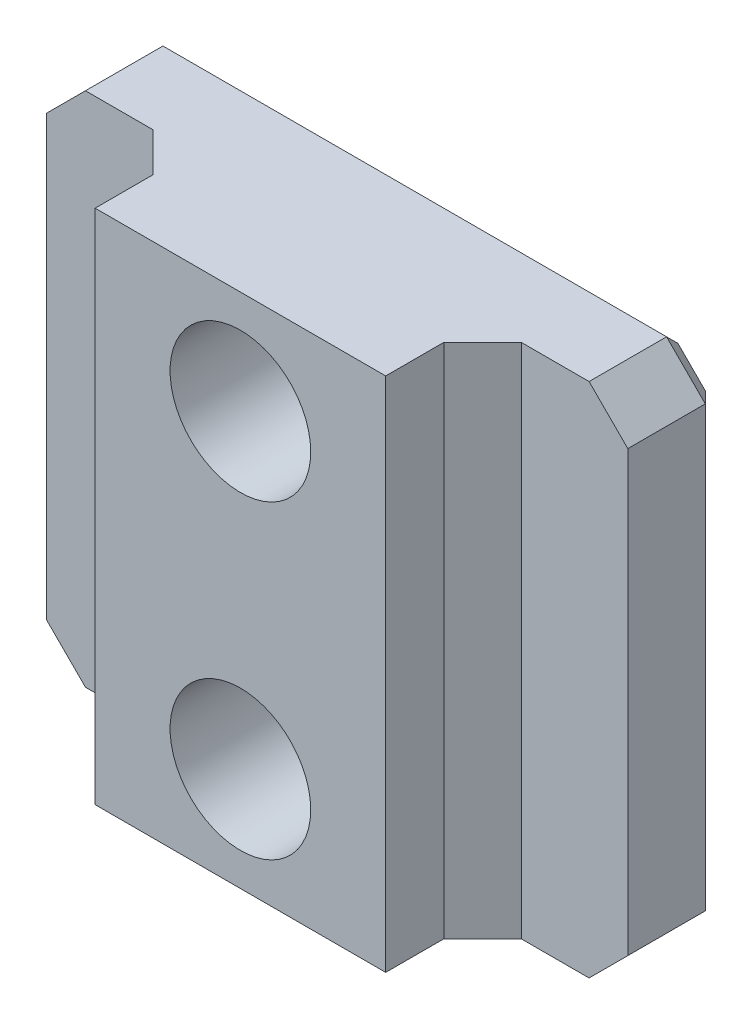
from build123d import *

# Parameters (mm, degrees)
SKETCH1_W               = 38.1
SKETCH1_H               = 33.86758938
BOSS_EXTRUDE1_DEPTH     = 12.7
F_1_4_CLEARANCE_HOLE1_D = 7.14248
HOLE1_AT_2_COUNT        = 2
HOLE1_AT_2_PITCH        = 20.32
SKETCH9_W               = 9.525
SKETCH9_H               = 6.35
CUT_EXTRUDE1_DEPTH      = 34.86758938
CHAMFER1_SIZE           = 2.54
CHAMFER2_SIZE           = 1.27


with BuildPart() as part:
    # Sketch1 → Boss-Extrude1 (new body)
    with BuildSketch(Plane.XY):
        with Locations((-124.004465969, 21.4125)):
            Rectangle(SKETCH1_W, SKETCH1_H)
    extrude(amount=BOSS_EXTRUDE1_DEPTH)

    # 1/4 Clearance Hole1 (through all)
    with Locations(Plane(origin=(0, 0, 0), x_dir=(-1, 0, 0), z_dir=(0, 0, -1))):
        with Locations((124.004465969, 11.2525), (124.004465969, 31.5725)):
            Hole(F_1_4_CLEARANCE_HOLE1_D / 2)

    # Sketch8 → Hole1 (revolve, cut)
    with BuildSketch(Plane(origin=(-124.004465969, 11.2525, 12.7), x_dir=(0, -1, 0), z_dir=(1, 0, 0))):
        Polygon((0, 0), (0, 7.62), (4.4323, 7.62), (4.6101, 0), align=None)
    hole1 = revolve(axis=Axis((-124.004465969, 11.2525, -97.3), (0, 0, 1)), mode=Mode.SUBTRACT)

    # Hole1 at 2: Hole1 ×2
    with Locations(*[(0, i * HOLE1_AT_2_PITCH, 0) for i in range(1, HOLE1_AT_2_COUNT)]):
        add(hole1, mode=Mode.SUBTRACT)

    # Sketch9 → Cut-Extrude1 (cut, through all)
    with BuildSketch(Plane.XZ.offset(-4.47870531)):
        with Locations((-109.716965969, 9.525)):
            Rectangle(SKETCH9_W, SKETCH9_H)
        with Locations((-138.291965969, 9.525)):
            Rectangle(SKETCH9_W, SKETCH9_H)
    extrude(amount=-CUT_EXTRUDE1_DEPTH, mode=Mode.SUBTRACT)

    # Chamfer1
    chamfer1_edges = [part.edges().sort_by_distance(p)[0] for p in [
        (-143.054465969, 38.34629469, 3.175),
        (-104.954465969, 38.34629469, 3.175),
        (-104.954465969, 4.47870531, 3.175),
        (-143.054465969, 4.47870531, 3.175),
        (-114.479465969, 21.4125, 6.35),
        (-133.529465969, 21.4125, 6.35),
    ]]
    chamfer(chamfer1_edges, length=CHAMFER1_SIZE)

    # Chamfer2
    chamfer2_edges = [part.edges().sort_by_distance(p)[0] for p in [
        (-143.054465969, 21.4125, 0),
        (-124.004465969, 38.34629469, 0),
        (-104.954465969, 21.4125, 0),
        (-124.004465969, 4.47870531, 0),
        (-106.224465969, 5.74870531, 0),
        (-141.784465969, 5.74870531, 0),
        (-106.224465969, 37.07629469, 0),
        (-141.784465969, 37.07629469, 0),
    ]]
    chamfer(chamfer2_edges, length=CHAMFER2_SIZE)


solid = part.part
